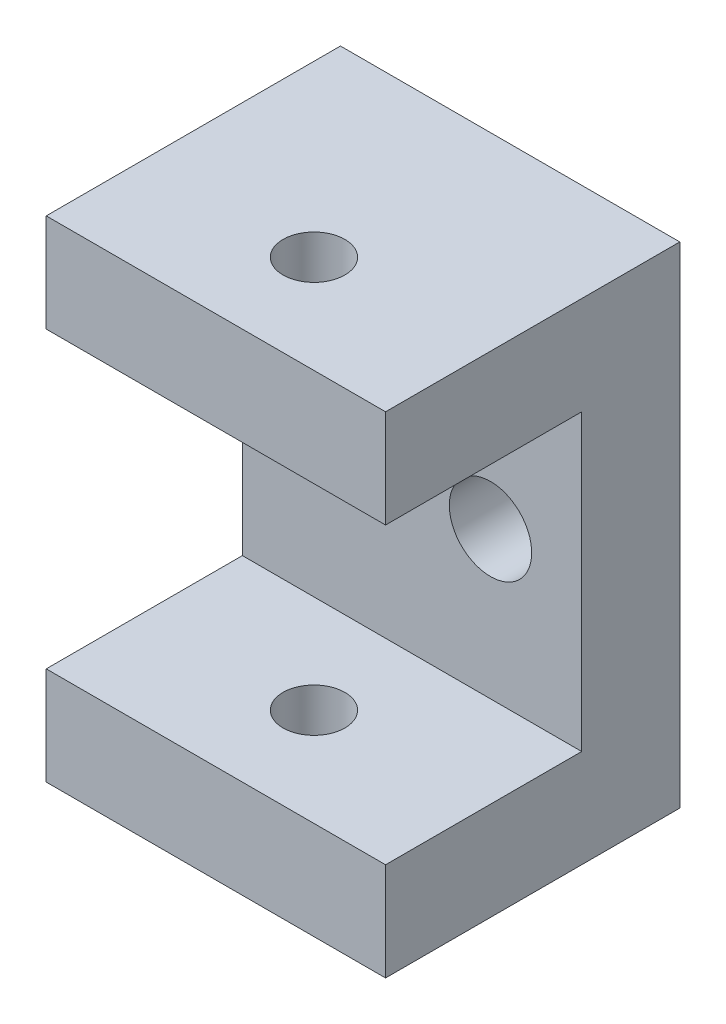
from build123d import *

# Parameters (mm, degrees)
SKETCH1_W           = 34.6
SKETCH1_H           = 50
SKETCH1_R           = 4.2
BOSS_EXTRUDE1_DEPTH = 30
SKETCH2_W           = 20
SKETCH2_H           = 30
CUT_EXTRUDE1_DEPTH  = 35.6
SKETCH3_R           = 3.15
CUT_EXTRUDE2_DEPTH  = 51


with BuildPart() as part:
    # Sketch1 → Boss-Extrude1 (new body)
    with BuildSketch(Plane.XY):
        Rectangle(SKETCH1_W, SKETCH1_H)
        with Locations((-8, 0)):
            Circle(SKETCH1_R, mode=Mode.SUBTRACT)
        with Locations((8, 0)):
            Circle(SKETCH1_R, mode=Mode.SUBTRACT)
    extrude(amount=BOSS_EXTRUDE1_DEPTH)

    # Sketch2 → Cut-Extrude1 (cut, through all)
    with BuildSketch(Plane.ZY.offset(17.3)):
        with Locations((20, 0)):
            Rectangle(SKETCH2_W, SKETCH2_H)
    extrude(amount=-CUT_EXTRUDE1_DEPTH, mode=Mode.SUBTRACT)

    # Sketch3 → Cut-Extrude2 (cut, through all)
    with BuildSketch(Plane(origin=(0, 25, 0), x_dir=(1, 0, 0), z_dir=(0, 1, 0))):
        with Locations((0, -20)):
            Circle(SKETCH3_R)
    extrude(amount=-CUT_EXTRUDE2_DEPTH, mode=Mode.SUBTRACT)


solid = part.part
